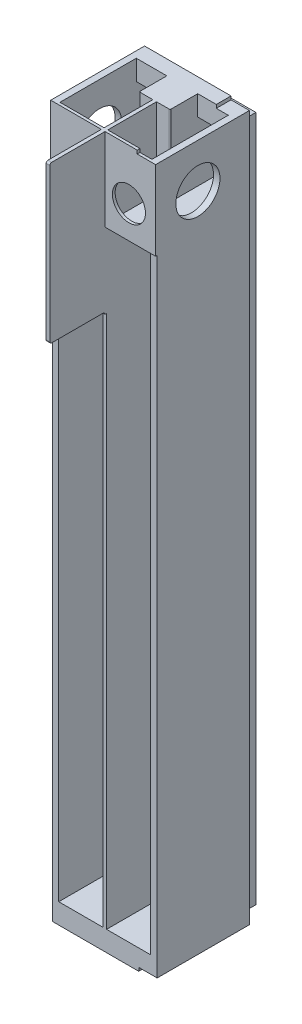
from build123d import *

# Parameters (mm, degrees)
SZKIC1_W                     = 53
SZKIC1_H                     = 374
SZKIC1_W_2                   = 24
SZKIC1_H_2                   = 365
DODANIE_WYCI_GNI_CIE2_DEPTH  = 12
SZKIC2_W                     = 12
SZKIC2_H                     = 3.5
WYTNIJ_WYCI_GNI_CIE1_DEPTH   = 2
SZKIC3_W                     = 53
SZKIC3_H                     = 374
DODANIE_WYCI_GNI_CIE3_DEPTH  = 2
SZKIC4_W                     = 13.3
SZKIC4_H                     = 30.500081729
SZKIC4_W_2                   = 9.4
SZKIC4_H_2                   = 64.96
WYTNIJ_WYCI_GNI_CIE2_DEPTH   = 2
SZKIC5_W                     = 2
SZKIC5_H                     = 374
DODANIE_WYCI_GNI_CIE4_DEPTH  = 43
DODANIE_WYCI_GNI_CIE5_DEPTH  = 41.5
SZKIC7_W                     = 25.5
SZKIC7_H                     = 38.500081729
DODANIE_WYCI_GNI_CIE6_DEPTH  = 1.5
SZKIC9_R                     = 12
WYTNIJ_WYCI_GNI_CIE4_DEPTH   = 1.5
DODANIE_WYCI_GNI_CIE7_DEPTH  = 43
DODANIE_WYCI_GNI_CIE8_DEPTH  = 43
SZKIC12_R                    = 12
WYTNIJ_WYCI_GNI_CIE5_DEPTH   = 1.5
SZKIC13_R                    = 9
WYTNIJ_WYCI_GNI_CIE6_DEPTH   = 1.5
SZKIC14_W                    = 57
SZKIC14_H                    = 374
SZKIC14_R                    = 12
DODANIE_WYCI_GNI_CIE9_DEPTH  = 1
SZKIC15_W                    = 57
SZKIC15_H                    = 374
SZKIC15_R                    = 12
DODANIE_WYCI_GNI_CIE10_DEPTH = 1
SZKIC16_W                    = 55
SZKIC16_H                    = 57
SZKIC16_W_2                  = 24
SZKIC16_H_2                  = 41.5
DODANIE_WYCI_GNI_CIE11_DEPTH = 1
SZKIC17_W                    = 55
SZKIC17_H                    = 57
DODANIE_WYCI_GNI_CIE12_DEPTH = 1
DODANIE_WYCI_GNI_CIE13_DEPTH = 30
SZKIC20_W                    = 55
SZKIC20_H                    = 57
DODANIE_WYCI_GNI_CIE14_DEPTH = 5.5
SZKIC21_W                    = 24
SZKIC21_H                    = 41.5
DODANIE_WYCI_GNI_CIE15_DEPTH = 5.5
SZKIC22_W                    = 57
SZKIC22_H                    = 387
SZKIC22_R                    = 12
DODANIE_WYCI_GNI_CIE16_DEPTH = 1
SZKIC23_W                    = 57
SZKIC23_H                    = 387
SZKIC23_R                    = 12
DODANIE_WYCI_GNI_CIE17_DEPTH = 1
ZAOKR_GLENIE1_R              = 1
ZAOKR_GLENIE2_R              = 1
ZAOKR_GLENIE3_R              = 1
SZKIC24_W                    = 57
SZKIC24_H                    = 387
SZKIC24_W_2                  = 52
SZKIC24_H_2                  = 373
WYTNIJ_WYCI_GNI_CIE7_DEPTH   = 6
SZKIC25_W                    = 24
SZKIC25_H                    = 330.999918271
WYTNIJ_WYCI_GNI_CIE8_DEPTH   = 2
SZKIC26_W                    = 10
SZKIC26_H                    = 51
WYTNIJ_WYCI_GNI_CIE9_DEPTH   = 1.85
SZKIC27_W                    = 10
SZKIC27_H                    = 51
WYTNIJ_WYCI_GNI_CIE10_DEPTH  = 1.85
WYTNIJ_WYCI_GNI_CIE11_DEPTH  = 0.85
WYTNIJ_WYCI_GNI_CIE12_DEPTH  = 2
WYTNIJ_WYCI_GNI_CIE13_DEPTH  = 2
SZKIC31_W                    = 2
SZKIC31_H                    = 3.5
WYTNIJ_WYCI_GNI_CIE14_DEPTH  = 16
DODANIE_WYCI_GNI_CIE18_DEPTH = 7.4
DODANIE_WYCI_GNI_CIE19_DEPTH = 7.4
SZKIC34_W                    = 7.4
SZKIC34_H                    = 11
DODANIE_WYCI_GNI_CIE20_DEPTH = 14
SZKIC35_W                    = 7.4
SZKIC35_H                    = 11
DODANIE_WYCI_GNI_CIE21_DEPTH = 14
SZKIC36_W                    = 2
SZKIC36_H                    = 34.000081729
DODANIE_WYCI_GNI_CIE22_DEPTH = 24
SZKIC37_W                    = 16.6
SZKIC37_H                    = 1.5
SZKIC37_W_2                  = 5.4
DODANIE_WYCI_GNI_CIE23_DEPTH = 8
SZKIC38_W                    = 7.4
SZKIC38_H                    = 43.500081729
WYTNIJ_WYCI_GNI_CIE15_DEPTH  = 1
ZAOKR_GLENIE4_R              = 0.5
ZAOKR_GLENIE5_R              = 0.5


with BuildPart() as part:
    # Szkic1 → Dodanie-wyciągnięcie2 (new body)
    with BuildSketch(Plane.XY):
        with Locations((-65.426891924, -133.239080048)):
            Rectangle(SZKIC1_W, SZKIC1_H)
        with Locations((-78.426891924, -133.239080048)):
            Rectangle(SZKIC1_W_2, SZKIC1_H_2, mode=Mode.SUBTRACT)
        with Locations((-52.426891924, -133.239080048)):
            Rectangle(SZKIC1_W_2, SZKIC1_H_2, mode=Mode.SUBTRACT)
    extrude(amount=DODANIE_WYCI_GNI_CIE2_DEPTH)

    # Szkic2 → Wytnij-wyciągnięcie1 (cut)
    with BuildSketch(Plane.ZY.offset(66.426891924)):
        with Locations((6, 47.510919952)):
            Rectangle(SZKIC2_W, SZKIC2_H)
    extrude(amount=-WYTNIJ_WYCI_GNI_CIE1_DEPTH, mode=Mode.SUBTRACT)

    # Szkic3 → Dodanie-wyciągnięcie3 (add)
    with BuildSketch(Plane.XY.offset(12)):
        with Locations((-65.426891924, -133.239080048)):
            Rectangle(SZKIC3_W, SZKIC3_H)
    extrude(amount=DODANIE_WYCI_GNI_CIE3_DEPTH)

    # Szkic4 → Wytnij-wyciągnięcie2 (cut)
    with BuildSketch(Plane.XY.offset(14)):
        Polygon((-46.926891924, -11.039080048), (-56.326891924, -11.039080048), (-56.326891924, -35.399080048), (-56.326891924, -40.479080048), (-46.926891924, -40.479080048), (-46.926891924, -35.399080048), align=None)
        with Locations((-47.076891924, 34.010879088)):
            Rectangle(SZKIC4_W, SZKIC4_H)
        with Locations((-83.776891924, 34.010879088)):
            Rectangle(SZKIC4_W, SZKIC4_H)
        Polygon((-74.526891924, -35.399080048), (-74.526891924, -11.039080048), (-83.926891924, -11.039080048), (-83.926891924, -35.399080048), (-83.926891924, -40.479080048), (-74.526891924, -40.479080048), align=None)
        with Locations((-51.626891924, -133.719080048)):
            Rectangle(SZKIC4_W_2, SZKIC4_H_2)
        with Locations((-79.226891924, -133.719080048)):
            Rectangle(SZKIC4_W_2, SZKIC4_H_2)
    extrude(amount=-WYTNIJ_WYCI_GNI_CIE2_DEPTH, mode=Mode.SUBTRACT)

    # Szkic5 → Dodanie-wyciągnięcie4 (add)
    with BuildSketch(Plane.XY.offset(14)):
        with Locations((-65.426891924, -133.239080048)):
            Rectangle(SZKIC5_W, SZKIC5_H)
    extrude(amount=DODANIE_WYCI_GNI_CIE4_DEPTH)

    # Szkic6 → Dodanie-wyciągnięcie5 (add)
    with BuildSketch(Plane.XY.offset(14)):
        Polygon((-64.426891924, 16.760838223), (-40.426891924, 16.760838223), (-40.426891924, 53.760919952), (-38.926891924, 53.760919952), (-38.926891924, 15.260838223), (-64.426891924, 15.260838223), align=None)
        Polygon((-90.426891924, 53.760919952), (-91.926891924, 53.760919952), (-91.926891924, 15.260838223), (-66.426891924, 15.260838223), (-66.426891924, 16.760838223), (-90.426891924, 16.760838223), align=None)
    extrude(amount=DODANIE_WYCI_GNI_CIE5_DEPTH)

    # Szkic7 → Dodanie-wyciągnięcie6 (add)
    with BuildSketch(Plane.XY.offset(55.5)):
        with Locations((-51.676891924, 34.510879088)):
            Rectangle(SZKIC7_W, SZKIC7_H)
        with Locations((-79.176891924, 34.510879088)):
            Rectangle(SZKIC7_W, SZKIC7_H)
    extrude(amount=DODANIE_WYCI_GNI_CIE6_DEPTH)

    # Szkic9 → Wytnij-wyciągnięcie4 (cut)
    with BuildSketch(Plane.ZY.offset(91.926891924)):
        with Locations((34, 34.510879088)):
            Circle(SZKIC9_R)
    extrude(amount=-WYTNIJ_WYCI_GNI_CIE4_DEPTH, mode=Mode.SUBTRACT)

    # Szkic10 → Dodanie-wyciągnięcie7 (add)
    with BuildSketch(Plane.XY.offset(14)):
        Polygon((-91.926891924, 15.260838223), (-91.926891924, -320.239080048), (-66.426891924, -320.239080048), (-66.426891924, -315.739080048), (-90.426891924, -315.739080048), (-90.426891924, 15.260838223), align=None)
    extrude(amount=DODANIE_WYCI_GNI_CIE7_DEPTH)

    # Szkic11 → Dodanie-wyciągnięcie8 (add)
    with BuildSketch(Plane.XY.offset(14)):
        Polygon((-38.926891924, 15.260838223), (-38.926891924, -320.239080048), (-64.426891924, -320.239080048), (-64.426891924, -315.739080048), (-40.426891924, -315.739080048), (-40.426891924, 15.260838223), align=None)
    extrude(amount=DODANIE_WYCI_GNI_CIE8_DEPTH)

    # Szkic12 → Wytnij-wyciągnięcie5 (cut)
    with BuildSketch(Plane(origin=(-38.926891924, 0, 0), x_dir=(0, 0, -1), z_dir=(1, 0, 0))):
        with Locations((-34, 34.510919952)):
            Circle(SZKIC12_R)
    extrude(amount=-WYTNIJ_WYCI_GNI_CIE5_DEPTH, mode=Mode.SUBTRACT)

    # Szkic13 → Wytnij-wyciągnięcie6 (cut)
    with BuildSketch(Plane.XY.offset(57)):
        with Locations((-51.426891924, 32.810879088)):
            Circle(SZKIC13_R)
        with Locations((-79.426891924, 32.810879088)):
            Circle(SZKIC13_R)
    extrude(amount=-WYTNIJ_WYCI_GNI_CIE6_DEPTH, mode=Mode.SUBTRACT)

    # Szkic14 → Dodanie-wyciągnięcie9 (add)
    with BuildSketch(Plane(origin=(-38.926891924, 0, 0), x_dir=(0, 0, -1), z_dir=(1, 0, 0))):
        with Locations((-28.5, -133.239080048)):
            Rectangle(SZKIC14_W, SZKIC14_H)
        with Locations((-34, 34.510919952)):
            Circle(SZKIC14_R, mode=Mode.SUBTRACT)
    extrude(amount=DODANIE_WYCI_GNI_CIE9_DEPTH)

    # Szkic15 → Dodanie-wyciągnięcie10 (add)
    with BuildSketch(Plane.ZY.offset(91.926891924)):
        with Locations((28.5, -133.239080048)):
            Rectangle(SZKIC15_W, SZKIC15_H)
        with Locations((34, 34.510879088)):
            Circle(SZKIC15_R, mode=Mode.SUBTRACT)
    extrude(amount=DODANIE_WYCI_GNI_CIE10_DEPTH)

    # Szkic16 → Dodanie-wyciągnięcie11 (add)
    with BuildSketch(Plane(origin=(0, 53.760919952, 0), x_dir=(1, 0, 0), z_dir=(0, 1, 0))):
        with Locations((-65.426891924, -28.5)):
            Rectangle(SZKIC16_W, SZKIC16_H)
        with Locations((-52.426891924, -34.75)):
            Rectangle(SZKIC16_W_2, SZKIC16_H_2, mode=Mode.SUBTRACT)
        with Locations((-78.426891924, -34.75)):
            Rectangle(SZKIC16_W_2, SZKIC16_H_2, mode=Mode.SUBTRACT)
    extrude(amount=DODANIE_WYCI_GNI_CIE11_DEPTH)

    # Szkic17 → Dodanie-wyciągnięcie12 (add)
    with BuildSketch(Plane.XZ.offset(320.239080048)):
        with Locations((-65.426891924, 28.5)):
            Rectangle(SZKIC17_W, SZKIC17_H)
    extrude(amount=DODANIE_WYCI_GNI_CIE12_DEPTH)

    # Szkic18 → Dodanie-wyciągnięcie13 (add)
    with BuildSketch(Plane.XY.offset(57)):
        Polygon((-64.426891924, 15.260838223), (-64.426891924, 54.760919952), (-66.426891924, 54.760919952), (-66.426891924, 15.260838223), (-66.426891924, -4.739161777), (-66.426891924, -24.739161777), (-64.426891924, -24.739161777), (-64.426891924, -4.739161777), align=None)
    extrude(amount=DODANIE_WYCI_GNI_CIE13_DEPTH)

    # Szkic20 → Dodanie-wyciągnięcie14 (add)
    with BuildSketch(Plane.XZ.offset(321.239080048)):
        with Locations((-65.426891924, 28.5)):
            Rectangle(SZKIC20_W, SZKIC20_H)
    extrude(amount=DODANIE_WYCI_GNI_CIE14_DEPTH)

    # Szkic21 → Dodanie-wyciągnięcie15 (add)
    with BuildSketch(Plane(origin=(0, 54.760919952, 0), x_dir=(1, 0, 0), z_dir=(0, 1, 0))):
        Polygon((-64.426891924, -87), (-66.426891924, -87), (-66.426891924, -57), (-92.926891924, -57), (-92.926891924, 0), (-37.926891924, 0), (-37.926891924, -57), (-64.426891924, -57), align=None)
        with Locations((-52.426891924, -34.75)):
            Rectangle(SZKIC21_W, SZKIC21_H, mode=Mode.SUBTRACT)
        with Locations((-78.426891924, -34.75)):
            Rectangle(SZKIC21_W, SZKIC21_H, mode=Mode.SUBTRACT)
    extrude(amount=DODANIE_WYCI_GNI_CIE15_DEPTH)

    # Szkic22 → Dodanie-wyciągnięcie16 (add)
    with BuildSketch(Plane(origin=(-37.926891924, 0, 0), x_dir=(0, 0, -1), z_dir=(1, 0, 0))):
        with Locations((-28.5, -133.239080048)):
            Rectangle(SZKIC22_W, SZKIC22_H)
        with Locations((-34, 34.510919952)):
            Circle(SZKIC22_R, mode=Mode.SUBTRACT)
    extrude(amount=DODANIE_WYCI_GNI_CIE16_DEPTH)

    # Szkic23 → Dodanie-wyciągnięcie17 (add)
    with BuildSketch(Plane.ZY.offset(92.926891924)):
        with Locations((28.5, -133.239080048)):
            Rectangle(SZKIC23_W, SZKIC23_H)
        with Locations((34, 34.510879088)):
            Circle(SZKIC23_R, mode=Mode.SUBTRACT)
    extrude(amount=DODANIE_WYCI_GNI_CIE17_DEPTH)

    # Zaokrąglenie1
    zaokr_glenie1_edges = [part.edges().sort_by_distance(p)[0] for p in [
        (-65.426891924, -24.739161777, 87),
    ]]
    fillet(zaokr_glenie1_edges, radius=ZAOKR_GLENIE1_R)

    # Zaokrąglenie2
    zaokr_glenie2_edges = [part.edges().sort_by_distance(p)[0] for p in [
        (-65.426891924, -24.739161777, 57),
    ]]
    fillet(zaokr_glenie2_edges, radius=ZAOKR_GLENIE2_R)

    # Zaokrąglenie3
    zaokr_glenie3_edges = [part.edges().sort_by_distance(p)[0] for p in [
        (-65.426891924, 60.260919952, 87),
    ]]
    fillet(zaokr_glenie3_edges, radius=ZAOKR_GLENIE3_R)

    # Szkic24 → Wytnij-wyciągnięcie7 (cut)
    with BuildSketch(Plane(origin=(0, 0, 0), x_dir=(-1, 0, 0), z_dir=(0, 0, -1))):
        with Locations((65.426891924, -133.239080048)):
            Rectangle(SZKIC24_W, SZKIC24_H)
        with Locations((65.426891924, -133.239080048)):
            Rectangle(SZKIC24_W_2, SZKIC24_H_2, mode=Mode.SUBTRACT)
    extrude(amount=-WYTNIJ_WYCI_GNI_CIE7_DEPTH, mode=Mode.SUBTRACT)

    # Szkic25 → Wytnij-wyciągnięcie8 (cut)
    with BuildSketch(Plane.XY.offset(14)):
        with Locations((-52.426891924, -150.239120912)):
            Rectangle(SZKIC25_W, SZKIC25_H)
        with Locations((-78.426891924, -150.239120912)):
            Rectangle(SZKIC25_W, SZKIC25_H)
    extrude(amount=-WYTNIJ_WYCI_GNI_CIE8_DEPTH, mode=Mode.SUBTRACT)

    # Szkic26 → Wytnij-wyciągnięcie9 (cut)
    with BuildSketch(Plane(origin=(0, 60.260919952, 0), x_dir=(1, 0, 0), z_dir=(0, 1, 0))):
        with Locations((-41.926891924, -31.5)):
            Rectangle(SZKIC26_W, SZKIC26_H)
    extrude(amount=-WYTNIJ_WYCI_GNI_CIE9_DEPTH, mode=Mode.SUBTRACT)

    # Szkic27 → Wytnij-wyciągnięcie10 (cut)
    with BuildSketch(Plane.XZ.offset(326.739080048)):
        with Locations((-41.926891924, 31.5)):
            Rectangle(SZKIC27_W, SZKIC27_H)
    extrude(amount=-WYTNIJ_WYCI_GNI_CIE10_DEPTH, mode=Mode.SUBTRACT)

    # Szkic28 → Wytnij-wyciągnięcie11 (cut)
    with BuildSketch(Plane.XY.offset(57)):
        Polygon((-36.926891924, -324.889080048), (-46.926891924, -324.889080048), (-46.926891924, -326.739080048), (-93.926891924, -326.739080048), (-93.926891924, 15.260838223), (-66.426891924, 15.260838223), (-66.426891924, -25.739161777), (-64.426891924, -25.739161777), (-64.426891924, 15.260838223), (-36.926891924, 15.260838223), align=None)
    extrude(amount=-WYTNIJ_WYCI_GNI_CIE11_DEPTH, mode=Mode.SUBTRACT)

    # Szkic29 → Wytnij-wyciągnięcie12 (cut)
    with BuildSketch(Plane.XY.offset(14)):
        Polygon((-40.426891924, 18.760838223), (-40.426891924, 16.760838223), (-64.426891924, 16.760838223), (-64.426891924, 49.260919952), (-53.726891924, 49.260919952), (-53.726891924, 18.760838223), align=None)
    extrude(amount=-WYTNIJ_WYCI_GNI_CIE12_DEPTH, mode=Mode.SUBTRACT)

    # Szkic30 → Wytnij-wyciągnięcie13 (cut)
    with BuildSketch(Plane.XY.offset(14)):
        Polygon((-77.126891924, 49.260919952), (-66.426891924, 49.260919952), (-66.426891924, 16.760838223), (-90.426891924, 16.760838223), (-90.426891924, 18.760838223), (-77.126891924, 18.760838223), align=None)
    extrude(amount=-WYTNIJ_WYCI_GNI_CIE13_DEPTH, mode=Mode.SUBTRACT)

    # Szkic31 → Wytnij-wyciągnięcie14 (cut)
    with BuildSketch(Plane(origin=(0, 0, 12), x_dir=(-1, 0, 0), z_dir=(0, 0, -1))):
        with Locations((65.426891924, 47.510919952)):
            Rectangle(SZKIC31_W, SZKIC31_H)
    extrude(amount=-WYTNIJ_WYCI_GNI_CIE14_DEPTH, mode=Mode.SUBTRACT)

    # Szkic32 → Dodanie-wyciągnięcie18 (add)
    with BuildSketch(Plane(origin=(-64.426891924, 0, 0), x_dir=(0, 0, -1), z_dir=(1, 0, 0))):
        Polygon((-28, 45.760919952), (-28, 16.760838223), (-30, 16.760838223), (-30, 60.260919952), (-28, 60.260919952), align=None)
    extrude(amount=DODANIE_WYCI_GNI_CIE18_DEPTH)

    # Szkic33 → Dodanie-wyciągnięcie19 (add)
    with BuildSketch(Plane.ZY.offset(66.426891924)):
        Polygon((28, 49.260919952), (28, 60.260919952), (30, 60.260919952), (30, 16.760838223), (28, 16.760838223), align=None)
    extrude(amount=DODANIE_WYCI_GNI_CIE19_DEPTH)

    # Szkic34 → Dodanie-wyciągnięcie20 (add)
    with BuildSketch(Plane.XY.offset(14)):
        with Locations((-60.726891924, 54.760919952)):
            Rectangle(SZKIC34_W, SZKIC34_H)
    extrude(amount=DODANIE_WYCI_GNI_CIE20_DEPTH)

    # Szkic35 → Dodanie-wyciągnięcie21 (add)
    with BuildSketch(Plane.XY.offset(14)):
        with Locations((-70.126891924, 54.760919952)):
            Rectangle(SZKIC35_W, SZKIC35_H)
    extrude(amount=DODANIE_WYCI_GNI_CIE21_DEPTH)

    # Szkic36 → Dodanie-wyciągnięcie22 (add)
    with BuildSketch(Plane(origin=(0, 0, 28), x_dir=(-1, 0, 0), z_dir=(0, 0, -1))):
        with Locations((58.026891924, 32.260879088)):
            Rectangle(SZKIC36_W, SZKIC36_H)
        with Locations((72.826891924, 32.260879088)):
            Rectangle(SZKIC36_W, SZKIC36_H)
    extrude(amount=DODANIE_WYCI_GNI_CIE22_DEPTH)

    # Szkic37 → Dodanie-wyciągnięcie23 (add)
    with BuildSketch(Plane(origin=(0, 0, 12), x_dir=(-1, 0, 0), z_dir=(0, 0, -1))):
        with Locations((48.726891924, 16.010838223)):
            Rectangle(SZKIC37_W, SZKIC37_H)
        with Locations((61.726891924, 16.010838223)):
            Rectangle(SZKIC37_W_2, SZKIC37_H)
        with Locations((69.126891924, 16.010838223)):
            Rectangle(SZKIC37_W_2, SZKIC37_H)
        with Locations((82.126891924, 16.010838223)):
            Rectangle(SZKIC37_W, SZKIC37_H)
    extrude(amount=DODANIE_WYCI_GNI_CIE23_DEPTH)

    # Szkic38 → Wytnij-wyciągnięcie15 (cut)
    with BuildSketch(Plane.XY.offset(30)):
        with Locations((-70.126891924, 38.510879088)):
            Rectangle(SZKIC38_W, SZKIC38_H)
        with Locations((-60.726891924, 38.510879088)):
            Rectangle(SZKIC38_W, SZKIC38_H)
    extrude(amount=-WYTNIJ_WYCI_GNI_CIE15_DEPTH, mode=Mode.SUBTRACT)

    # Zaokrąglenie4
    zaokr_glenie4_edges = [part.edges().sort_by_distance(p)[0] for p in [
        (-57.026891924, 38.510879088, 29),
    ]]
    fillet(zaokr_glenie4_edges, radius=ZAOKR_GLENIE4_R)

    # Zaokrąglenie5
    zaokr_glenie5_edges = [part.edges().sort_by_distance(p)[0] for p in [
        (-73.826891924, 38.510879088, 29),
    ]]
    fillet(zaokr_glenie5_edges, radius=ZAOKR_GLENIE5_R)


solid = part.part
